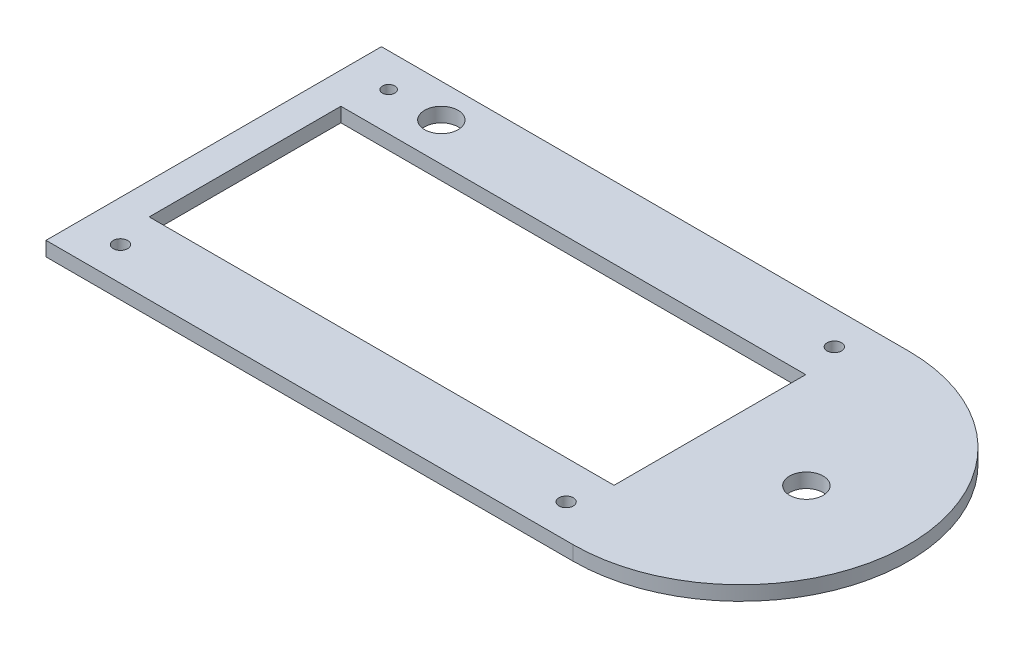
from build123d import *

# Parameters (mm, degrees)
SKETCH1_R           = 1.3
SKETCH1_R_2         = 1.5
SKETCH1_R_3         = 3.5
SKETCH1_W           = 97
SKETCH1_H           = 40
BOSS_EXTRUDE1_DEPTH = 3


with BuildPart() as part:
    # Sketch1 → Boss-Extrude1 (new body)
    with BuildSketch(Plane(origin=(0, 0, 0), x_dir=(1, 0, 0), z_dir=(0, 1, 0))):
        with BuildLine():
            Line((-67.43171984, 21.978952762), (42.56828016, 21.978952762))
            ThreePointArc((42.56828016, 21.978952762), (77.56828016, -13.021047238), (42.56828016, -48.021047238))
            Line((42.56828016, -48.021047238), (-67.43171984, -48.021047238))
            Line((-67.43171984, -48.021047238), (-67.43171984, 21.978952762))
        make_face()
        with Locations((-58.93171984, 14.978952762)):
            Circle(SKETCH1_R, mode=Mode.SUBTRACT)
        with Locations((34.06828016, 14.978952762)):
            Circle(SKETCH1_R_2, mode=Mode.SUBTRACT)
        with Locations((-58.895119552, -41.021035277)):
            Circle(SKETCH1_R_2, mode=Mode.SUBTRACT)
        with Locations((34.104880448, -41.021035277)):
            Circle(SKETCH1_R_2, mode=Mode.SUBTRACT)
        with Locations((56.242935444, -13.021047238)):
            Circle(SKETCH1_R_3, mode=Mode.SUBTRACT)
        with Locations((-47.93171984, 14.978952762)):
            Circle(SKETCH1_R_3, mode=Mode.SUBTRACT)
        with Locations((-12.395119552, -13.021047238)):
            Rectangle(SKETCH1_W, SKETCH1_H, mode=Mode.SUBTRACT)
    extrude(amount=BOSS_EXTRUDE1_DEPTH)


solid = part.part
